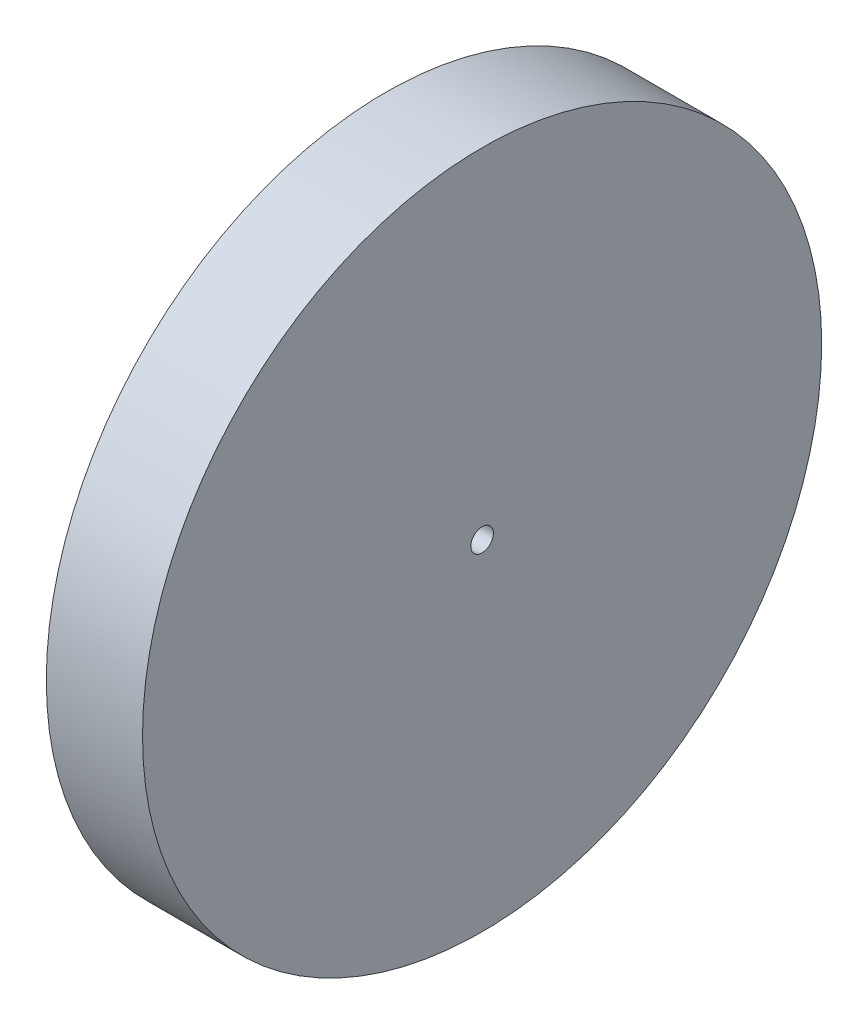
from build123d import *

# Parameters (mm, degrees)
BASPROSKE_W        = 12
BASPROSKE_H        = 12
TOOTHCUT_DEPTH     = 86.697141143
TEETHCUTS_COUNT    = 50
ESQUISSE1_R        = 60
ESQUISSE1_R_2      = 2
BOSS_EXTRU_1_DEPTH = 5


with BuildPart() as part:
    # BasProSke → Base-Revolve (revolve)
    with BuildSketch(Plane(origin=(0, 0, 0), x_dir=(1, 0, 0), z_dir=(0, 1, 0)), mode=Mode.PRIVATE) as base_revolve_sk:
        with Locations((6, 54)):
            Rectangle(BASPROSKE_W, BASPROSKE_H)
    revolve(base_revolve_sk.sketch.rotate(Axis((-10, 0, 0), (1, 0, 0)), 180), axis=Axis((-10, 0, 0), (1, 0, 0)))

    # TooCutSke → ToothCut (cut, through all)
    with BuildSketch(Plane(origin=(0, 0, 0), x_dir=(0, 0, -1), z_dir=(1, 0, 0))):
        with BuildLine():
            ThreePointArc((2.426707814, 47.913185391), (1.628356337, 50.250450788), (0.603274723, 52.497533853))
            ThreePointArc((0.603274723, 52.497533853), (0, 52.501), (-0.603274723, 52.497533853))
            ThreePointArc((-0.603274723, 52.497533853), (-1.628356337, 50.250450788), (-2.426707814, 47.913185391))
            ThreePointArc((-2.426707814, 47.913185391), (0, 47.9746), (2.426707814, 47.913185391))
        make_face()
    toothcut = extrude(amount=TOOTHCUT_DEPTH, mode=Mode.SUBTRACT)

    # TeethCuts: ToothCut ×50 about axis
    teethcuts_axis = Axis((0, 0, 0), (1, 0, 0))
    for i in range(1, TEETHCUTS_COUNT):
        add(toothcut.rotate(teethcuts_axis, i * 360 / TEETHCUTS_COUNT), mode=Mode.SUBTRACT)

    # Esquisse1 → Boss.-Extru.1 (add)
    with BuildSketch(Plane(origin=(12, 0, 0), x_dir=(0, 0, -1), z_dir=(1, 0, 0))):
        with Locations(Location((0, 0, 0), (0, 0, 180))):
            Circle(ESQUISSE1_R)
        Circle(ESQUISSE1_R_2, mode=Mode.SUBTRACT)
    extrude(amount=BOSS_EXTRU_1_DEPTH)


solid = part.part
